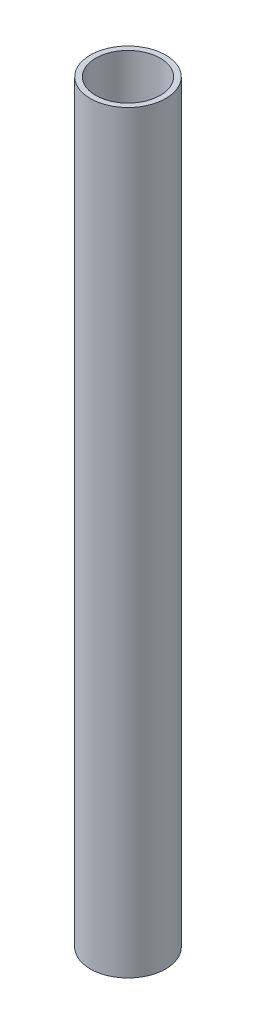
from build123d import *

# Parameters (mm, degrees)
SKETCH_1_R      = 7
SKETCH_1_R_2    = 6
EXTRUDE_1_DEPTH = 140


with BuildPart() as part:
    # Эскиз1 → Бобышка-Вытянуть1 (new body)
    with BuildSketch(Plane(origin=(0, 0, 0), x_dir=(1, 0, 0), z_dir=(0, 1, 0))):
        Circle(SKETCH_1_R)
        Circle(SKETCH_1_R_2, mode=Mode.SUBTRACT)
    extrude(amount=EXTRUDE_1_DEPTH)


solid = part.part
